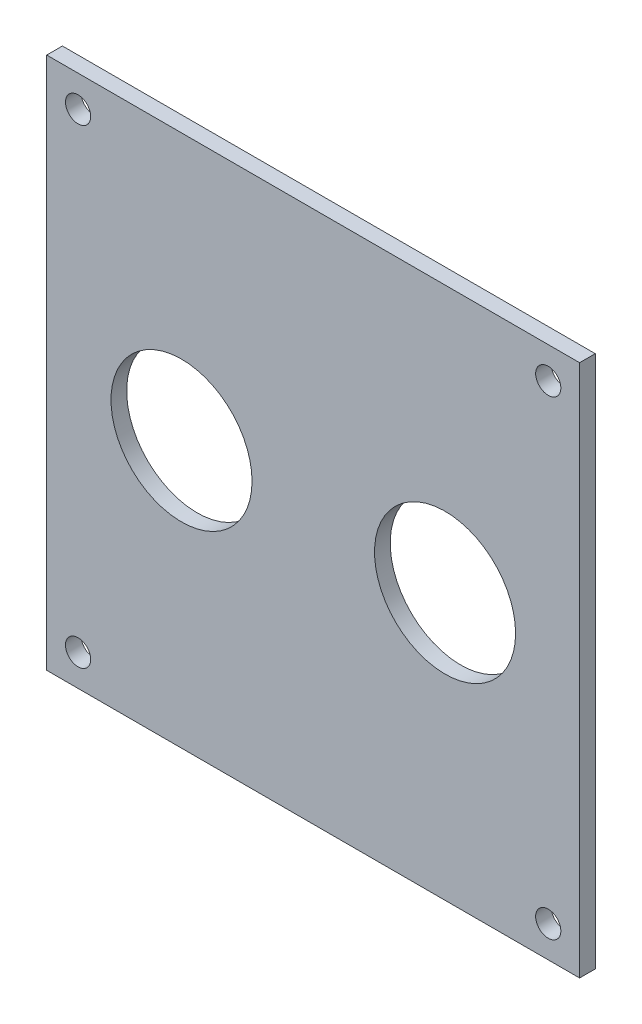
from build123d import *

# Parameters (mm, degrees)
SKETCH1_W           = 107.95
SKETCH1_H           = 107.95
BOSS_EXTRUDE1_DEPTH = 3.175
SKETCH2_R           = 2.5527
CUT_EXTRUDE1_DEPTH  = 3.175
SKETCH3_R           = 14.2875
CUT_EXTRUDE2_DEPTH  = 3.175


with BuildPart() as part:
    # Sketch1 → Boss-Extrude1 (new body)
    with BuildSketch(Plane.XY):
        with Locations((53.975, 53.975)):
            Rectangle(SKETCH1_W, SKETCH1_H)
    extrude(amount=BOSS_EXTRUDE1_DEPTH)

    # Sketch2 → Cut-Extrude1 (cut)
    with BuildSketch(Plane(origin=(0, 0, 0), x_dir=(-1, 0, 0), z_dir=(0, 0, -1))):
        with Locations((-6.35, 101.6)):
            Circle(SKETCH2_R)
        with Locations((-101.6, 101.6)):
            Circle(SKETCH2_R)
        with Locations((-101.6, 6.35)):
            Circle(SKETCH2_R)
        with Locations((-6.35, 6.35)):
            Circle(SKETCH2_R)
    extrude(amount=-CUT_EXTRUDE1_DEPTH, mode=Mode.SUBTRACT)

    # Sketch3 → Cut-Extrude2 (cut)
    with BuildSketch(Plane.XY.offset(3.175)):
        with Locations((27.305, 53.975)):
            Circle(SKETCH3_R)
        with Locations((80.6958, 53.975)):
            Circle(SKETCH3_R)
    extrude(amount=-CUT_EXTRUDE2_DEPTH, mode=Mode.SUBTRACT)


solid = part.part
